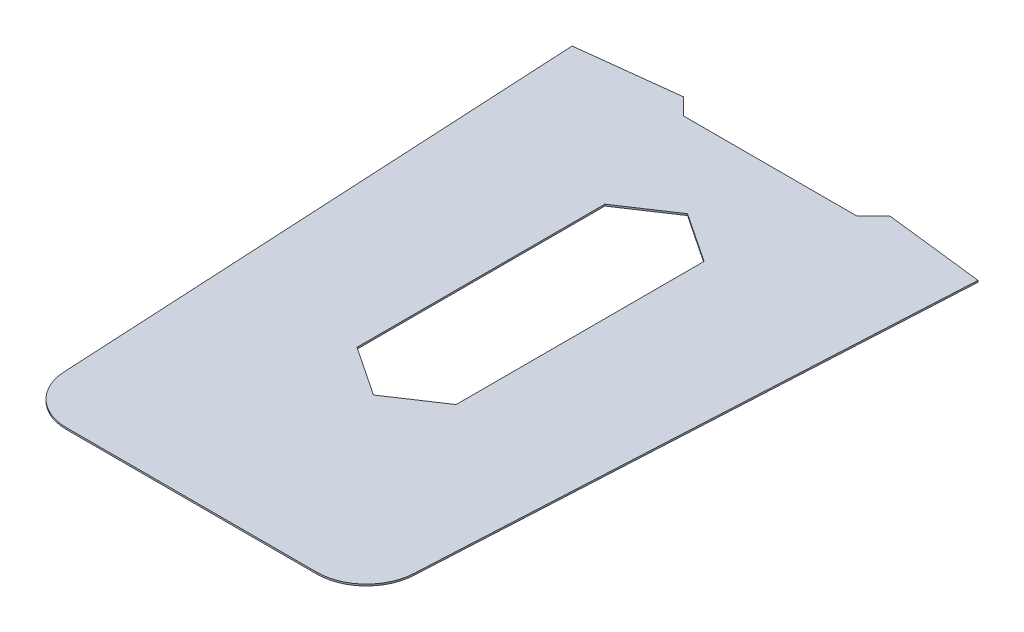
from build123d import *

# Parameters (mm, degrees)
BOSS_EXTRUDE1_DEPTH = 1.27


with BuildPart() as part:
    # Sketch1 → Boss-Extrude1 (new body)
    with BuildSketch(Plane(origin=(0, 0, 0), x_dir=(1, 0, 0), z_dir=(0, 1, 0))):
        with BuildLine():
            Line((-152.4, 120.65), (-139.7, -120.65))
            Line((-139.7, -120.65), (-134.247237287, -224.252491542))
            ThreePointArc((-134.247237287, -224.252491542), (-122.423123118, -249.88969001), (-96.19989799, -260.35))
            Line((-96.19989799, -260.35), (0, -260.35))
            Line((0, -260.35), (96.19989799, -260.35))
            ThreePointArc((96.19989799, -260.35), (122.423123118, -249.88969001), (134.247237287, -224.252491542))
            Line((134.247237287, -224.252491542), (139.7, -120.65))
            Line((139.7, -120.65), (152.4, 120.65))
            Line((152.4, 120.65), (155.939618828, 187.902757734))
            Line((155.939618828, 187.902757734), (79.375, 196.85))
            Line((79.375, 196.85), (66.675, 184.15))
            Line((66.675, 184.15), (0, 184.15))
            Line((0, 184.15), (-66.675, 184.15))
            Line((-66.675, 184.15), (-79.375, 196.85))
            Line((-79.375, 196.85), (-155.939618828, 187.902757734))
            Line((-155.939618828, 187.902757734), (-152.4, 120.65))
        make_face()
        Polygon((-38.1, 95.25), (0, 120.65), (38.1, 95.25), (38.1, -95.25), (0, -120.65), (-38.1, -95.25), align=None, mode=Mode.SUBTRACT)
    extrude(amount=BOSS_EXTRUDE1_DEPTH)


solid = part.part
